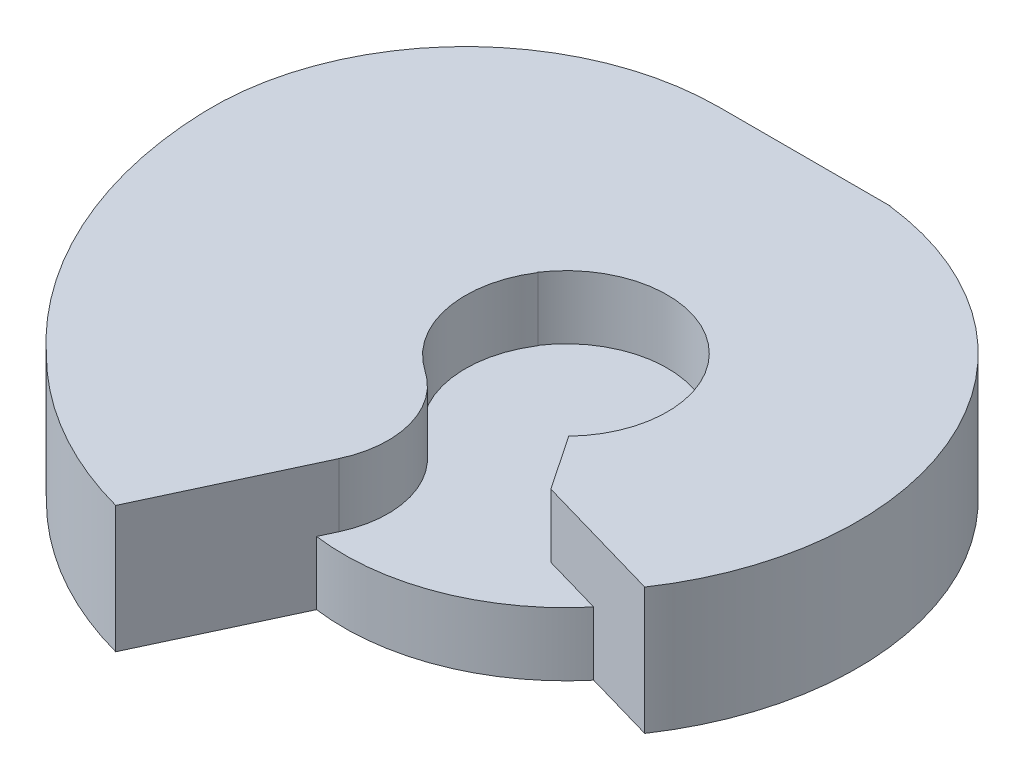
from build123d import *

# Parameters (mm, degrees)
SKETCH1_R           = 8.89
BOSS_EXTRUDE1_DEPTH = 2.54
BOSS_EXTRUDE2_DEPTH = 5.08


with BuildPart() as part:
    # Sketch1 → Boss-Extrude1 (new body)
    with BuildSketch(Plane(origin=(0, 0, 0), x_dir=(1, 0, 0), z_dir=(0, 1, 0))):
        Circle(SKETCH1_R)
    extrude(amount=BOSS_EXTRUDE1_DEPTH)

    # Sketch2 → Boss-Extrude2 (add)
    with BuildSketch(Plane.XZ):
        with BuildLine():
            Line((-5.470156896, -11.616175324), (1.370506729, -11.61329797))
            Line((1.370506729, -11.61329797), (1.370502542, -11.603343431))
            ThreePointArc((1.370502542, -11.603343431), (10.619701794, -4.872144272), (9.689428275, 6.529229334))
            Line((9.689428275, 6.529229334), (4.409313475, 5.011855517))
            Line((4.409313475, 5.011855517), (2.930122665, 2.816110291))
            ThreePointArc((2.930122665, 2.816110291), (2.540155429, -3.172334534), (-3.388651254, -2.243465774))
            Line((-3.388651254, -2.243465774), (-3.366867699, -2.245362356))
            ThreePointArc((-3.366867699, -2.245362356), (-3.942300227, 0.830594917), (-2.207502202, 3.435035653))
            ThreePointArc((-2.207502202, 3.435035653), (-0.675671449, 5.575210871), (-0.89674169, 8.197801836))
            Line((-0.89674169, 8.197801836), (-3.743562754, 14.29613097))
            ThreePointArc((-3.743562754, 14.29613097), (-7.273662922, 12.829288696), (-10.310746752, 10.507790201))
            ThreePointArc((-10.310746752, 10.507790201), (-14.139706345, 5.222375996), (-15.629256563, -1.131974878))
            ThreePointArc((-15.629256563, -1.131974878), (-12.770870955, -8.526364048), (-5.470156896, -11.616175324))
        make_face()
    extrude(amount=-BOSS_EXTRUDE2_DEPTH)


solid = part.part
